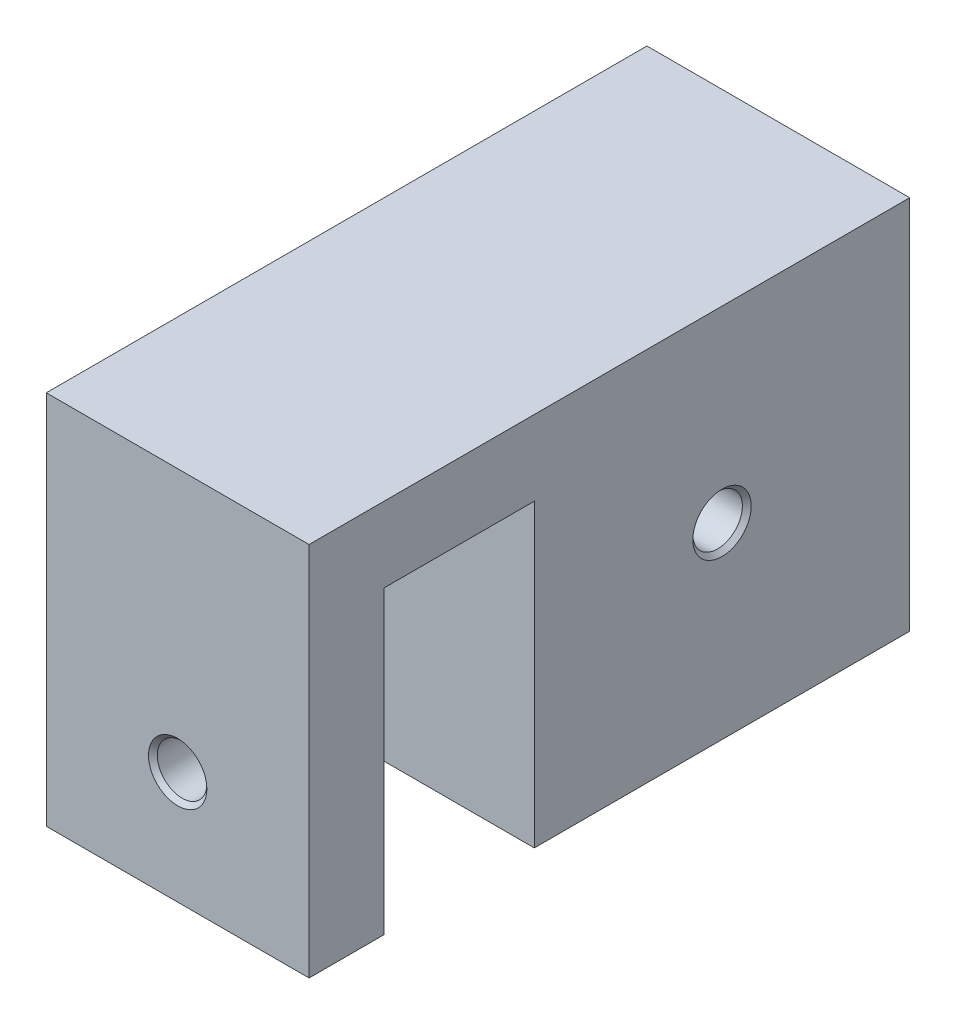
from build123d import *

# Parameters (mm, degrees)
SKETCH_2_W                      = 50
SKETCH_2_H                      = 50
EXTRUDE_1_DEPTH                 = 35
SKETCH_3_R                      = 20
CUT_EXTRUDE_1_DEPTH             = 20
HOLE_WIZARD_G1_16_1_D           = 6.6
HOLE_WIZARD_G1_16_1_DEPTH       = 20
HOLE_WIZARD_G1_16_1_CSINK_D     = 7.773
HOLE_WIZARD_G1_16_1_CSINK_ANGLE = 90
HOLE_WIZARD_G1_16_1_TIP         = 1.982840043
SKETCH_14_W                     = 35
SKETCH_14_H                     = 10
EXTRUDE_4_DEPTH                 = 30
SKETCH_15_W                     = 35
SKETCH_15_H                     = 10
EXTRUDE_5_DEPTH                 = 40
HOLE_WIZARD_G1_16_2_D           = 6.6
HOLE_WIZARD_G1_16_2_DEPTH       = 20
HOLE_WIZARD_G1_16_2_CSINK_D     = 7.773
HOLE_WIZARD_G1_16_2_CSINK_ANGLE = 90
HOLE_WIZARD_G1_16_2_TIP         = 1.982840043


with BuildPart() as part:
    # 草图2 → 凸台-拉伸1 (new body)
    with BuildSketch(Plane(origin=(0, 0, 0), x_dir=(0, 0, -1), z_dir=(1, 0, 0))):
        with Locations((25, -25)):
            Rectangle(SKETCH_2_W, SKETCH_2_H)
    extrude(amount=EXTRUDE_1_DEPTH)

    # 草图3 → 切除-拉伸1 (cut)
    with BuildSketch(Plane.ZY):
        with Locations((-25, -25)):
            Circle(SKETCH_3_R)
    extrude(amount=-CUT_EXTRUDE_1_DEPTH, mode=Mode.SUBTRACT)

    # G1/16 螺纹孔1
    with Locations(Plane(origin=(35, 0, 0), x_dir=(0, 0, -1), z_dir=(1, 0, 0))):
        with Locations((25, -25)):
            CounterSinkHole(HOLE_WIZARD_G1_16_1_D / 2, HOLE_WIZARD_G1_16_1_CSINK_D / 2, depth=HOLE_WIZARD_G1_16_1_DEPTH, counter_sink_angle=HOLE_WIZARD_G1_16_1_CSINK_ANGLE)
            with Locations((0, 0, -(HOLE_WIZARD_G1_16_1_DEPTH + HOLE_WIZARD_G1_16_1_TIP / 2))):  # 118° drill point
                Cone(0, HOLE_WIZARD_G1_16_1_D / 2, HOLE_WIZARD_G1_16_1_TIP, mode=Mode.SUBTRACT)

    # 草图14 → 凸台-拉伸4 (add)
    with BuildSketch(Plane.XY):
        with Locations((17.5, -5)):
            Rectangle(SKETCH_14_W, SKETCH_14_H)
    extrude(amount=EXTRUDE_4_DEPTH)

    # 草图15 → 凸台-拉伸5 (add)
    with BuildSketch(Plane(origin=(0, -10, 0), x_dir=(-1, 0, 0), z_dir=(0, -1, 0))):
        with Locations((-17.5, -25)):
            Rectangle(SKETCH_15_W, SKETCH_15_H)
    extrude(amount=EXTRUDE_5_DEPTH)

    # G1/16 螺纹孔2
    with Locations(Plane.XY.offset(30)):
        with Locations((17.5, -35)):
            CounterSinkHole(HOLE_WIZARD_G1_16_2_D / 2, HOLE_WIZARD_G1_16_2_CSINK_D / 2, depth=HOLE_WIZARD_G1_16_2_DEPTH, counter_sink_angle=HOLE_WIZARD_G1_16_2_CSINK_ANGLE)
            with Locations((0, 0, -(HOLE_WIZARD_G1_16_2_DEPTH + HOLE_WIZARD_G1_16_2_TIP / 2))):  # 118° drill point
                Cone(0, HOLE_WIZARD_G1_16_2_D / 2, HOLE_WIZARD_G1_16_2_TIP, mode=Mode.SUBTRACT)


solid = part.part
